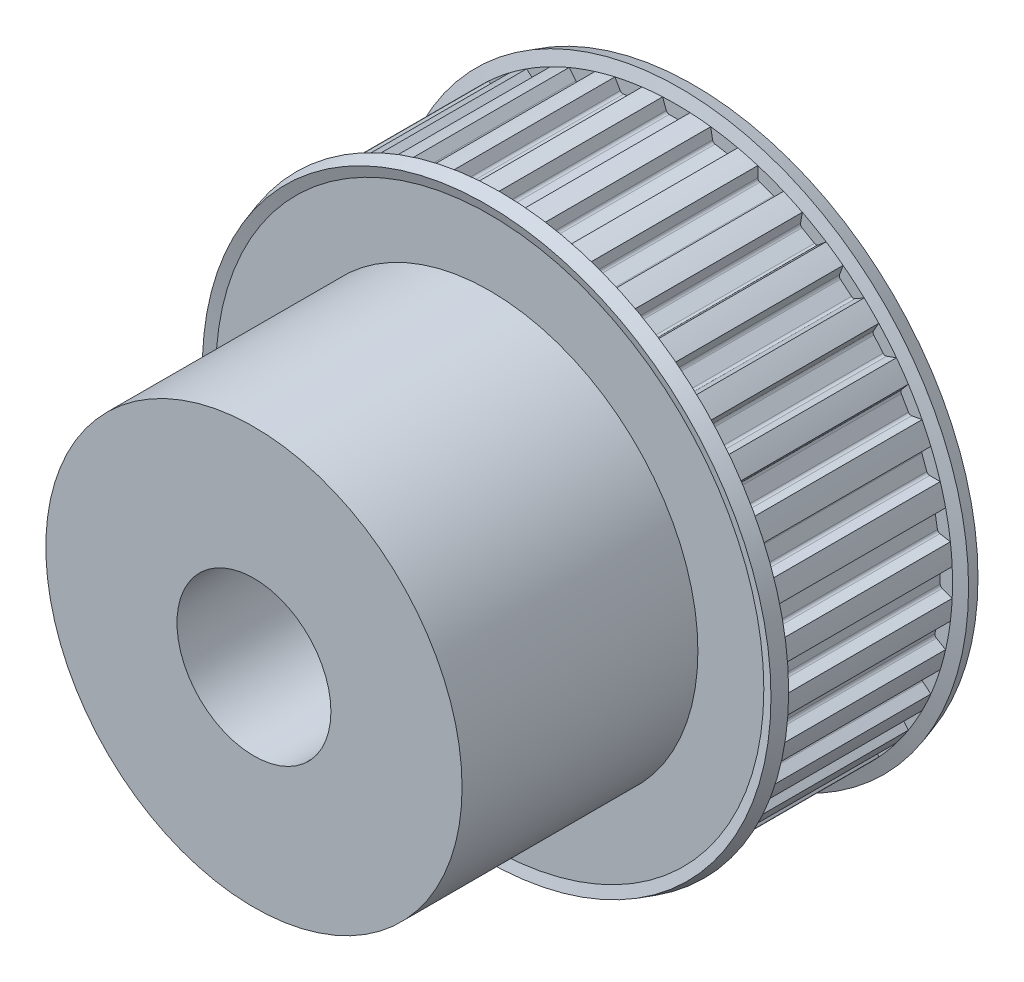
from build123d import *

# Parameters (mm, degrees)
SKETCH1_R        = 11.3919
BASEPULLEY_DEPTH = 7.112
GROOVE_DEPTH     = 3.556
GROOVES_COUNT    = 36
GROOVES_ANGLE    = 350
SKETCH4_W        = 10.3124
SKETCH4_H        = 8.5852
BORSKE_R         = 3.175
BORE_DEPTH       = 19.138384425


with BuildPart() as part:
    # Sketch1 → BasePulley (new body)
    with BuildSketch(Plane.XY):
        Circle(SKETCH1_R)
    extrude(amount=-BASEPULLEY_DEPTH)

    # Sketch2 → Flange (revolve)
    with BuildSketch(Plane(origin=(0, 0, 0), x_dir=(0, 0, -1), z_dir=(1, 0, 0))):
        Polygon((7.112, 11.3919), (7.267311186, 11.8999), (7.825984425, 11.72909645), (7.6962, 11.304590725), (7.6962, 0), (-0.5842, 0), (-0.5842, 11.304590725), (-0.713984425, 11.72909645), (-0.155311186, 11.8999), (0, 11.3919), align=None)
    revolve(axis=Axis((0, 0, 0), (0, 0, -1)))

    # Sketch3 → Groove (cut, symmetric)
    with BuildSketch(Plane.XY.offset(-3.556)):
        with BuildLine():
            Line((-0.5715, 11.3919), (-0.5715, 36.7919))
            Line((-0.5715, 36.7919), (0.5715, 36.7919))
            Line((0.5715, 36.7919), (0.5715, 11.3919))
            Line((0.5715, 11.3919), (0.417017726, 10.967463442))
            ThreePointArc((0.417017726, 10.967463442), (0.370520971, 10.90686769), (0.297676764, 10.8839))
            Line((0.297676764, 10.8839), (-0.297676764, 10.8839))
            ThreePointArc((-0.297676764, 10.8839), (-0.370520971, 10.90686769), (-0.417017726, 10.967463442))
            Line((-0.417017726, 10.967463442), (-0.5715, 11.3919))
        make_face()
    groove = extrude(amount=GROOVE_DEPTH, both=True, mode=Mode.SUBTRACT)

    # Grooves: Groove ×36 about axis
    grooves_axis = Axis((0, 0, -7.112), (0, 0, 1))
    for i in range(1, GROOVES_COUNT):
        add(groove.rotate(grooves_axis, i * GROOVES_ANGLE / (GROOVES_COUNT - 1)), mode=Mode.SUBTRACT)

    # Sketch4 → BaseHub (revolve)
    with BuildSketch(Plane(origin=(0, 0, 0), x_dir=(0, 0, -1), z_dir=(1, 0, 0))):
        with Locations((-5.1562, 4.2926)):
            Rectangle(SKETCH4_W, SKETCH4_H)
    revolve(axis=Axis((0, 0, 0), (0, 0, -1)))

    # BorSke → Bore (cut, through all)
    with BuildSketch(Plane.XY.offset(10.3124)):
        Circle(BORSKE_R)
    extrude(amount=-BORE_DEPTH, mode=Mode.SUBTRACT)


solid = part.part
